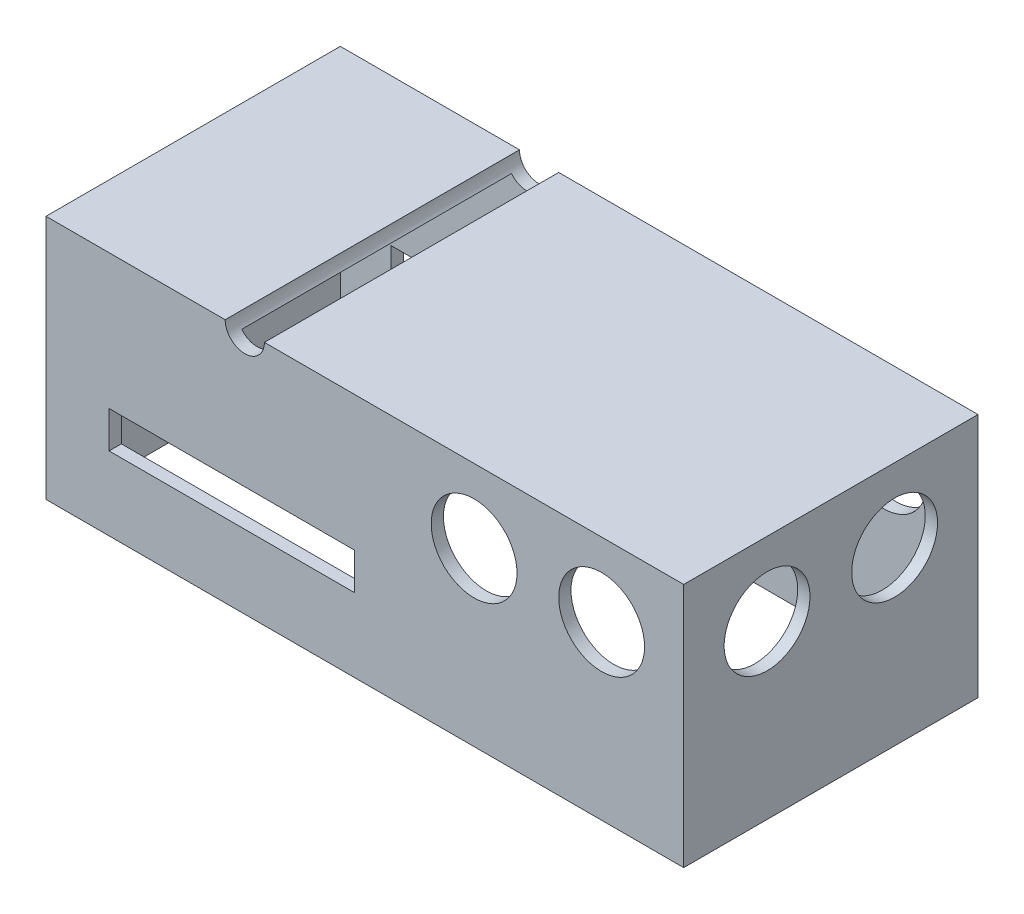
from build123d import *

# Parameters (mm, degrees)
SKETCH1_W           = 130
SKETCH1_H           = 60
BOSS_EXTRUDE2_DEPTH = 50
SHELL1_T            = -2.5
CUT_EXTRUDE1_REACH  = 132
SKETCH2_R           = 8.75
SKETCH3_R           = 8.75
CUT_EXTRUDE2_DEPTH  = 61
SKETCH4_W           = 50
SKETCH4_H           = 7.5
CUT_EXTRUDE3_DEPTH  = 61
CUT_EXTRUDE4_DEPTH  = 61


with BuildPart() as part:
    # Sketch1 → Boss-Extrude2 (new body)
    with BuildSketch(Plane(origin=(0, 0, 0), x_dir=(1, 0, 0), z_dir=(0, 1, 0))):
        Rectangle(SKETCH1_W, SKETCH1_H)
    extrude(amount=BOSS_EXTRUDE2_DEPTH)

    # Shell1
    shell1_openings = [part.faces().sort_by_distance(p)[0] for p in [
        (0, 0, 0),
    ]]
    offset(amount=SHELL1_T, openings=shell1_openings, kind=Kind.INTERSECTION)

    # Sketch2 → Cut-Extrude1 (cut, up to next)
    with BuildSketch(Plane(origin=(65, 0, 0), x_dir=(0, 0, -1), z_dir=(1, 0, 0)), mode=Mode.PRIVATE) as cut_extrude1_sk1:
        with Locations((-13, 35)):
            Circle(SKETCH2_R)
    cut_extrude1_tool1 = extrude(cut_extrude1_sk1.sketch, amount=-CUT_EXTRUDE1_REACH, mode=Mode.PRIVATE) & part.part
    add(cut_extrude1_tool1.solids().sort_by_distance((65, 35, 13))[0], mode=Mode.SUBTRACT)
    # Sketch2 → Cut-Extrude1 (cut, up to next)
    with BuildSketch(Plane(origin=(65, 0, 0), x_dir=(0, 0, -1), z_dir=(1, 0, 0)), mode=Mode.PRIVATE) as cut_extrude1_sk2:
        with BuildLine():
            ThreePointArc((21.75, 35), (13, 43.75), (4.25, 35))
            ThreePointArc((4.25, 35), (13, 26.25), (21.75, 35))
        make_face()
    cut_extrude1_tool2 = extrude(cut_extrude1_sk2.sketch, amount=-CUT_EXTRUDE1_REACH, mode=Mode.PRIVATE) & part.part
    add(cut_extrude1_tool2.solids().sort_by_distance((65, 35, -13))[0], mode=Mode.SUBTRACT)

    # Sketch3 → Cut-Extrude2 (cut, through all)
    with BuildSketch(Plane.XY.offset(30)):
        with Locations((22.274243645, 35)):
            Circle(SKETCH3_R)
        with Locations((48.274243645, 35)):
            Circle(SKETCH3_R)
    extrude(amount=-CUT_EXTRUDE2_DEPTH, mode=Mode.SUBTRACT)

    # Sketch4 → Cut-Extrude3 (cut, through all)
    with BuildSketch(Plane(origin=(0, 0, -30), x_dir=(-1, 0, 0), z_dir=(0, 0, -1))):
        with Locations((27.140672083, 18.75)):
            Rectangle(SKETCH4_W, SKETCH4_H)
    extrude(amount=-CUT_EXTRUDE3_DEPTH, mode=Mode.SUBTRACT)

    # Sketch5 → Cut-Extrude4 (cut, through all)
    with BuildSketch(Plane(origin=(0, 0, -30), x_dir=(-1, 0, 0), z_dir=(0, 0, -1))):
        with BuildLine():
            Line((20.475756355, 50), (28.475756355, 50))
            ThreePointArc((28.475756355, 50), (24.475756355, 46), (20.475756355, 50))
        make_face()
    extrude(amount=-CUT_EXTRUDE4_DEPTH, mode=Mode.SUBTRACT)


solid = part.part
